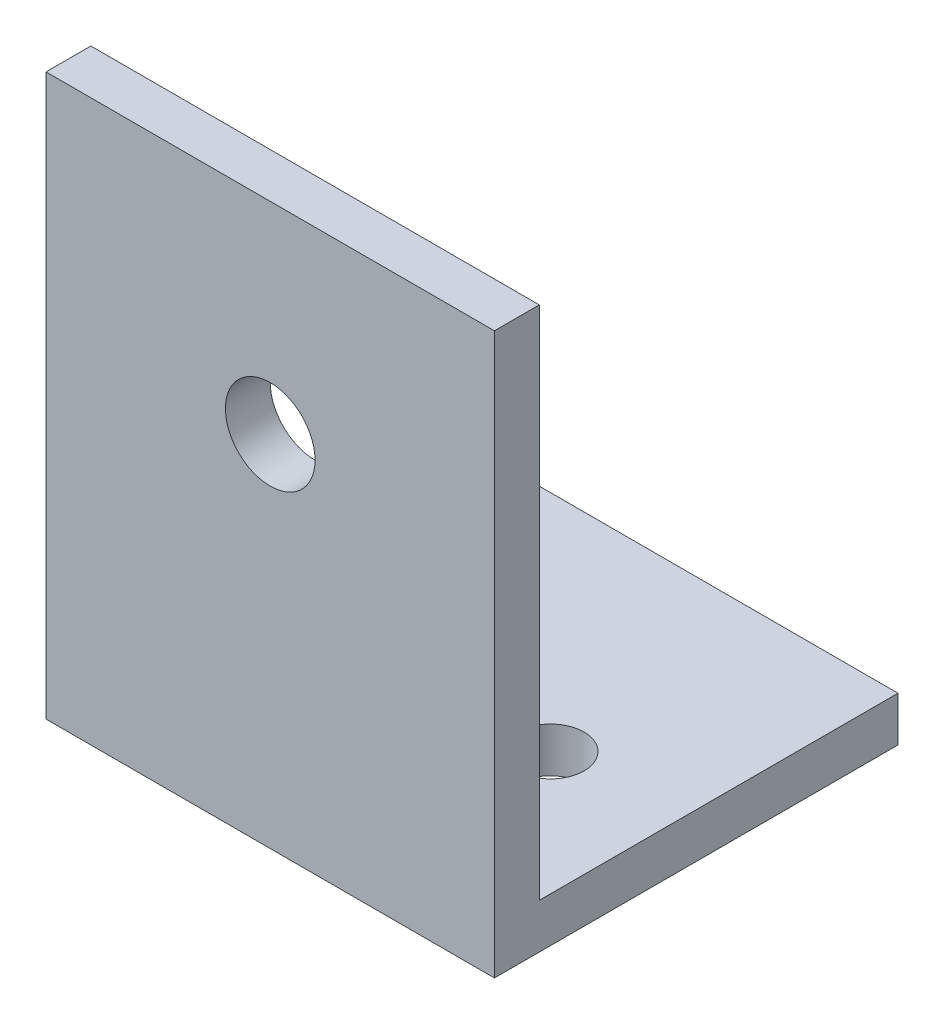
from build123d import *

# Parameters (mm, degrees)
EXTRUDE_1_DEPTH     = 20
SKETCH_2_R          = 1.5
CUT_EXTRUDE_1_DEPTH = 4
SKETCH_3_R          = 2
CUT_EXTRUDE_2_DEPTH = 19
SKETCH_4_W          = 20
SKETCH_4_H          = 15
CUT_EXTRUDE_3_DEPTH = 1
SKETCH_5_W          = 20
SKETCH_5_H          = 23
CUT_EXTRUDE_4_DEPTH = 1


with BuildPart() as part:
    # 草图1 → 凸台-拉伸1 (new body)
    with BuildSketch(Plane(origin=(0, 0, 0), x_dir=(0, 0, -1), z_dir=(1, 0, 0))):
        Polygon((0, 0), (0, 25), (3, 25), (3, 3), (18, 3), (18, 0), align=None)
    extrude(amount=EXTRUDE_1_DEPTH)

    # 草图2 → 切除-拉伸1 (cut, through all)
    with BuildSketch(Plane(origin=(0, 3, 0), x_dir=(1, 0, 0), z_dir=(0, 1, 0))):
        with Locations((5.5, 8)):
            Circle(SKETCH_2_R)
        with Locations((14.5, 8)):
            Circle(SKETCH_2_R)
    extrude(amount=-CUT_EXTRUDE_1_DEPTH, mode=Mode.SUBTRACT)

    # 草图3 → 切除-拉伸2 (cut, through all)
    with BuildSketch(Plane.XY):
        with Locations((10, 16)):
            Circle(SKETCH_3_R)
    extrude(amount=-CUT_EXTRUDE_2_DEPTH, mode=Mode.SUBTRACT)

    # 草图4 → 切除-拉伸3 (cut)
    with BuildSketch(Plane(origin=(0, 3, 0), x_dir=(1, 0, 0), z_dir=(0, 1, 0))):
        with Locations((10, 10.5)):
            Rectangle(SKETCH_4_W, SKETCH_4_H)
    extrude(amount=-CUT_EXTRUDE_3_DEPTH, mode=Mode.SUBTRACT)

    # 草图5 → 切除-拉伸4 (cut)
    with BuildSketch(Plane(origin=(0, 0, -3), x_dir=(-1, 0, 0), z_dir=(0, 0, -1))):
        with Locations((-10, 13.5)):
            Rectangle(SKETCH_5_W, SKETCH_5_H)
    extrude(amount=-CUT_EXTRUDE_4_DEPTH, mode=Mode.SUBTRACT)


solid = part.part
